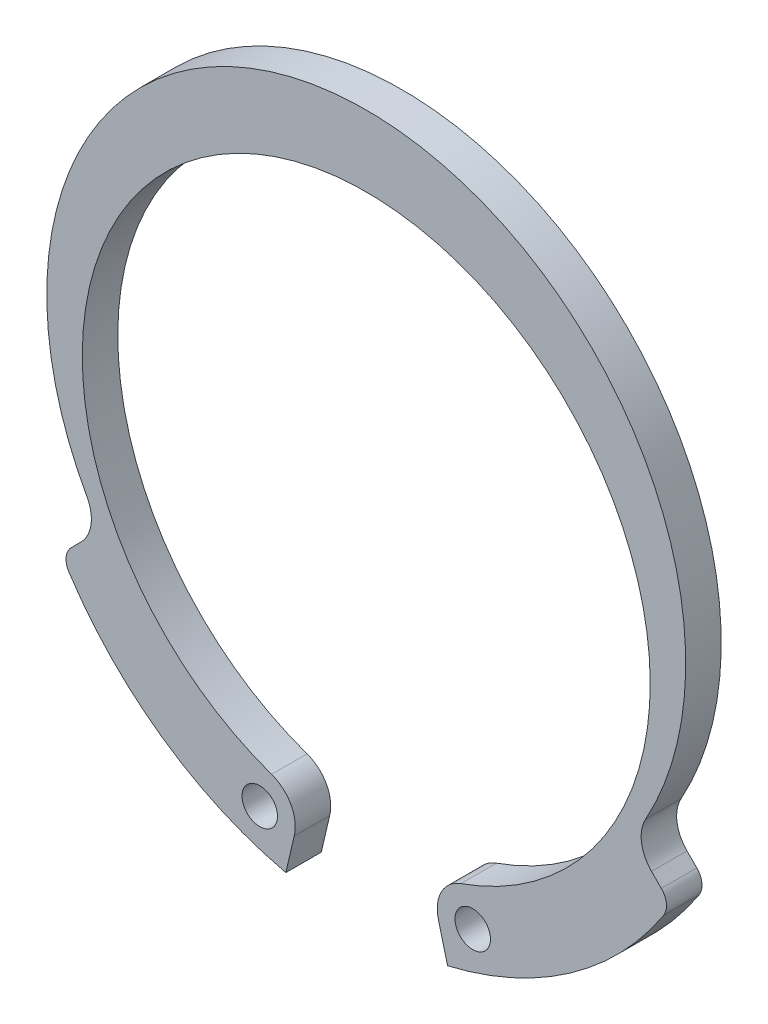
from build123d import *

# Parameters (mm, degrees)
SKETCH1_R           = 0.5
BOSS_EXTRUDE1_DEPTH = 1


with BuildPart() as part:
    # Sketch1 → Boss-Extrude1 (new body)
    with BuildSketch(Plane.XY):
        with BuildLine():
            Line((-8.036806523, -5.559320723), (-8.311889028, -5.834403228))
            ThreePointArc((-8.311889028, -5.834403228), (-8.455641966, -6.136125974), (-8.377195408, -6.461006967))
            ThreePointArc((-8.377195408, -6.461006967), (-5.735345972, -9.191813388), (-2.265503441, -10.739994567))
            Line((-2.265503441, -10.739994567), (-2.032287486, -9.737337896))
            ThreePointArc((-2.032287486, -9.737337896), (-2.116763903, -9.016352811), (-2.666666667, -8.542472333))
            ThreePointArc((-2.666666667, -8.542472333), (0, 7), (2.666666667, -8.542472333))
            ThreePointArc((2.666666667, -8.542472333), (2.116763903, -9.016352811), (2.032287486, -9.737337896))
            Line((2.032287486, -9.737337896), (2.291840404, -10.733831084))
            ThreePointArc((2.291840404, -10.733831084), (5.746419561, -9.184049256), (8.377195408, -6.461006967))
            ThreePointArc((8.377195408, -6.461006967), (8.455641966, -6.136125974), (8.311889028, -5.834403228))
            Line((8.311889028, -5.834403228), (8.036806523, -5.559320723))
            ThreePointArc((8.036806523, -5.559320723), (7.753612497, -4.991153897), (7.869521974, -4.366992547))
            ThreePointArc((7.869521974, -4.366992547), (0, 9), (-7.869521974, -4.366992547))
            ThreePointArc((-7.869521974, -4.366992547), (-7.753612497, -4.991153897), (-8.036806523, -5.559320723))
        make_face()
        with Locations((-3, -9.485281374)):
            Circle(SKETCH1_R, mode=Mode.SUBTRACT)
        with Locations((3, -9.485281374)):
            Circle(SKETCH1_R, mode=Mode.SUBTRACT)
    extrude(amount=BOSS_EXTRUDE1_DEPTH)


solid = part.part
